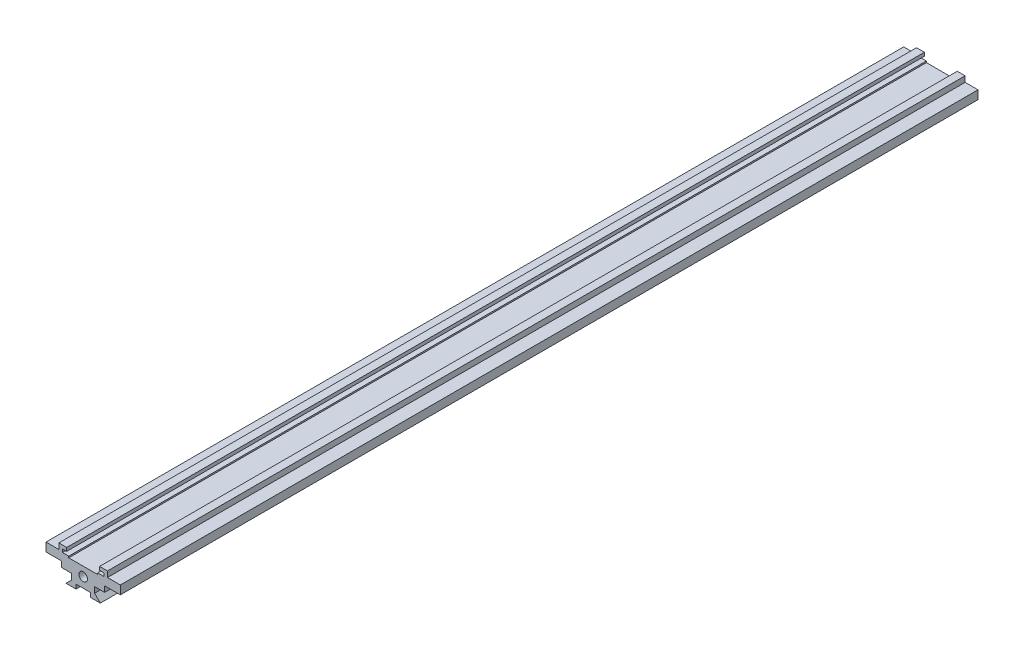
from build123d import *

# Parameters (mm, degrees)
EXTRUDE_1_DEPTH     = 150
SKETCH_2_R          = 1.5
CUT_EXTRUDE_1_DEPTH = 6
CUT_EXTRUDE_3_REACH = 302
SKETCH_4_W          = 5
SKETCH_4_H          = 1.5


with BuildPart() as part:
    # 草图1 → 凸台-拉伸1 (new body, symmetric)
    with BuildSketch(Plane.XY):
        Polygon((13, 6), (7.5, 6), (7.5, 4), (4, 4), (4, 2), (6, 0), (-6, 0), (-4, 2), (-4, 4), (-7.5, 4), (-7.5, 6), (-13, 6), (-13, 9), (-8.5, 9), (-8.5, 11), (-5.75, 11), (-5.75, 9.8), (-7.25, 9.8), (-7.25, 8.7), (-5.05, 8.7), (-5.05, 8.2), (5.05, 8.2), (5.05, 8.7), (7.25, 8.7), (7.25, 9.8), (5.75, 9.8), (5.75, 11), (8.5, 11), (8.5, 9), (13, 9), align=None)
    extrude(amount=EXTRUDE_1_DEPTH, both=True)

    # 草图2 → 切除-拉伸1 (cut)
    with BuildSketch(Plane(origin=(0, 0, -150), x_dir=(-1, 0, 0), z_dir=(0, 0, -1))):
        with Locations((0, 5)):
            Circle(SKETCH_2_R)
    cut_extrude_1 = extrude(amount=-CUT_EXTRUDE_1_DEPTH, mode=Mode.SUBTRACT)

    # 草图4 → 切除-拉伸3 (cut, up to next)
    with BuildSketch(Plane.XY.offset(150), mode=Mode.PRIVATE) as cut_extrude_3_sk1:
        with Locations((0, 0.75)):
            Rectangle(SKETCH_4_W, SKETCH_4_H)
    cut_extrude_3_tool1 = extrude(cut_extrude_3_sk1.sketch, amount=-CUT_EXTRUDE_3_REACH, mode=Mode.PRIVATE) & part.part
    add(cut_extrude_3_tool1.solids().sort_by_distance((0, 0.75, 150))[0], mode=Mode.SUBTRACT)

    # 镜向1: 切除-拉伸1 across plane
    add(cut_extrude_1.mirror(Plane.XY), mode=Mode.SUBTRACT)


solid = part.part
